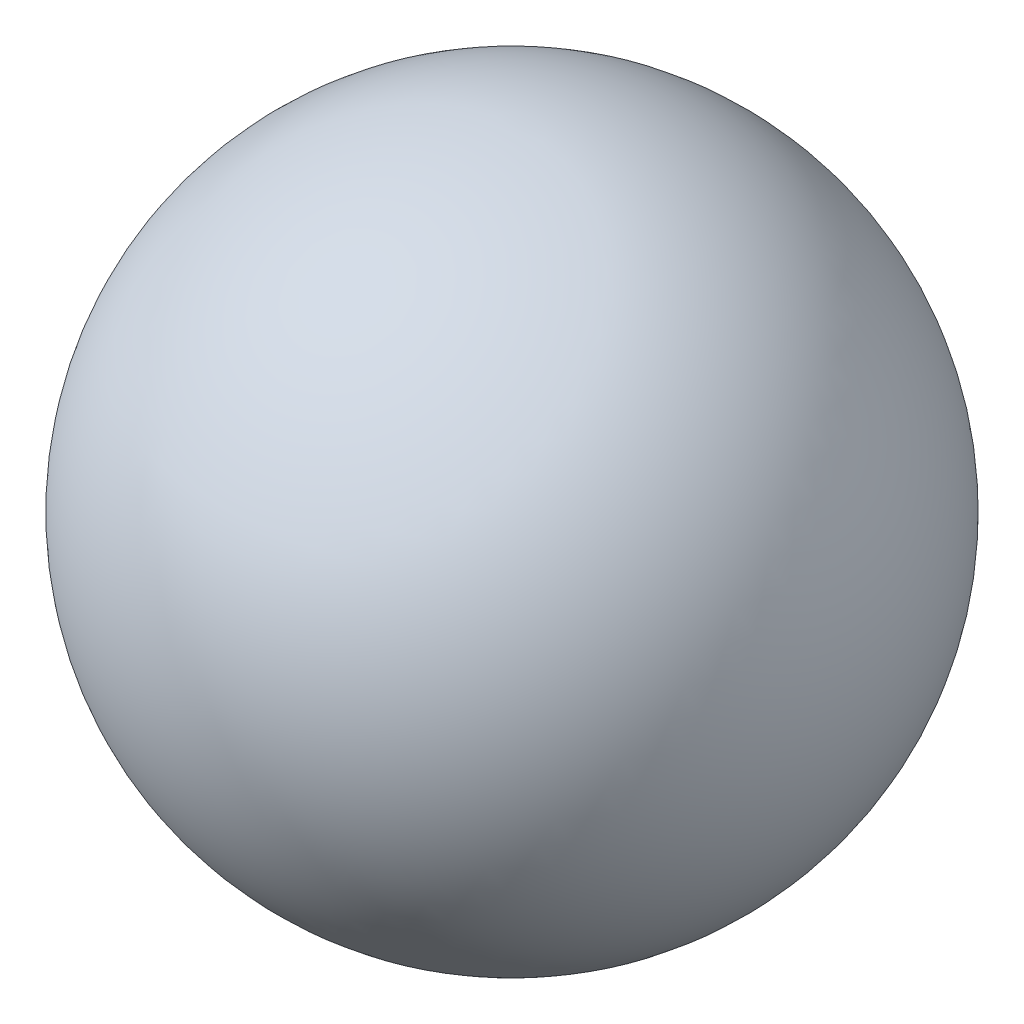
from build123d import *


with BuildPart() as part:
    # Sketch2 → Revolve-Thin1 (revolve)
    with BuildSketch(Plane.XY):
        with BuildLine():
            ThreePointArc((0, 600), (300, 300), (0, 0))
            Line((0, 0), (0, 0.03))
            ThreePointArc((0, 0.03), (299.97, 300), (0, 599.97))
            Line((0, 599.97), (0, 600))
        make_face()
    revolve(axis=Axis((0, 0, 0), (0, 1, 0)))


solid = part.part
